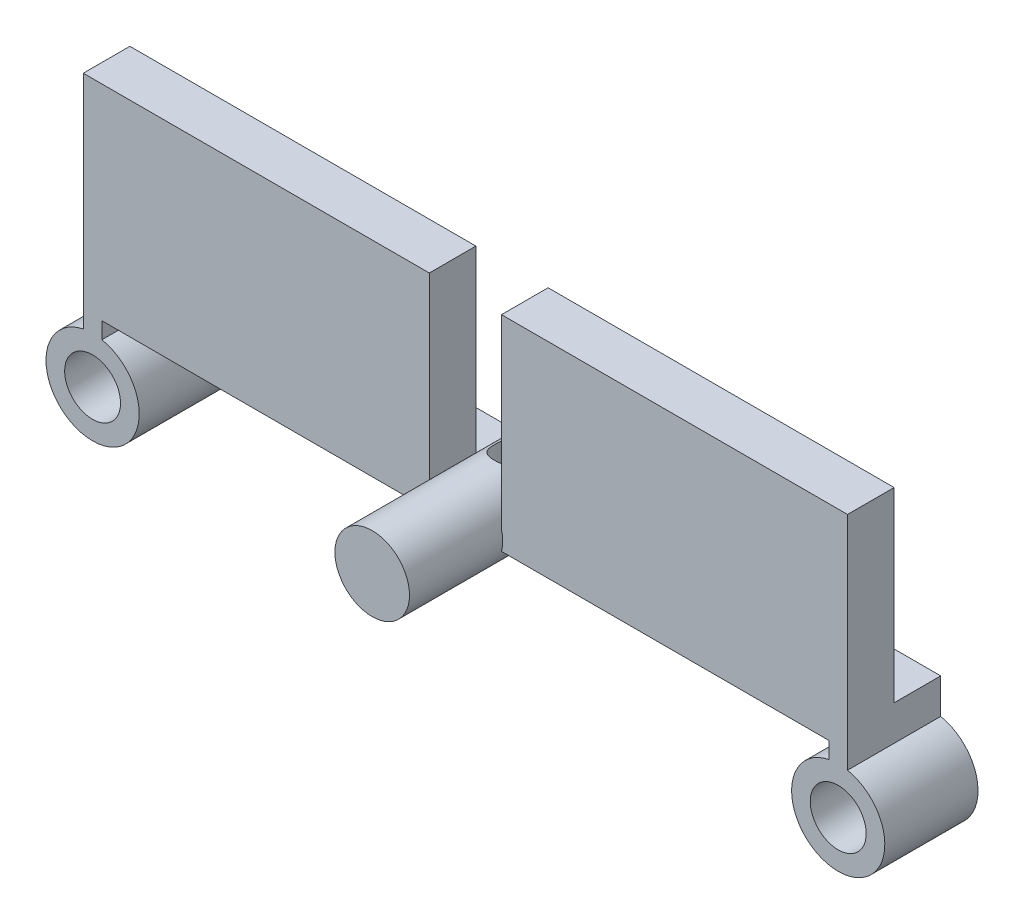
from build123d import *

# Parameters (mm, degrees)
SKETCH1_R                      = 6
BOSS_EXTRUDE1_DEPTH            = 30
SKETCH2_R                      = 4.5
BOSS_EXTRUDE2_DEPTH            = 15
CUT_EXTRUDE1_REACH             = 21
SKETCH3_R                      = 2.868632687
CUT_EXTRUDE1_DIRECTION_2_REACH = 8
SKETCH4_W                      = 55.690524981
SKETCH4_H                      = 7.5
BOSS_EXTRUDE3_DEPTH            = 30


with BuildPart() as part:
    # Sketch1 → Boss-Extrude1 (new body)
    with BuildSketch(Plane.XY):
        Circle(SKETCH1_R)
    extrude(amount=BOSS_EXTRUDE1_DEPTH)

    # Sketch2 → Boss-Extrude2 (add)
    with BuildSketch(Plane.XY):
        with BuildLine():
            Line((6, -1.5), (58.5, -1.5))
            Line((58.5, -1.5), (58.5, -4.151530772))
            ThreePointArc((58.5, -4.151530772), (60, -19), (61.5, -4.151530772))
            Line((61.5, -4.151530772), (61.5, 1.5))
            Line((61.5, 1.5), (6, 1.5))
            Line((6, 1.5), (5.809475019, 1.5))
            ThreePointArc((5.809475019, 1.5), (6, 0), (5.809475019, -1.5))
            Line((5.809475019, -1.5), (6, -1.5))
        make_face()
        with Locations((60, -11.5)):
            Circle(SKETCH2_R, mode=Mode.SUBTRACT)
        with BuildLine():
            Line((-58.5, -1.5), (-58.5, -4.151530772))
            ThreePointArc((-58.5, -4.151530772), (-60, -19), (-61.5, -4.151530772))
            Line((-61.5, -4.151530772), (-61.5, 1.5))
            Line((-61.5, 1.5), (-6, 1.5))
            Line((-6, 1.5), (-5.809475019, 1.5))
            ThreePointArc((-5.809475019, 1.5), (-6, 0), (-5.809475019, -1.5))
            Line((-5.809475019, -1.5), (-6, -1.5))
            Line((-6, -1.5), (-58.5, -1.5))
        make_face()
        with Locations((-60, -11.5)):
            Circle(SKETCH2_R, mode=Mode.SUBTRACT)
    extrude(amount=BOSS_EXTRUDE2_DEPTH)

    # Sketch3 → Cut-Extrude1 (cut, up to next)
    with BuildSketch(Plane(origin=(0, 0, 0), x_dir=(1, 0, 0), z_dir=(0, 1, 0)), mode=Mode.PRIVATE) as cut_extrude1_sk1:
        with Locations((0, -7.5)):
            Circle(SKETCH3_R)
    cut_extrude1_tool1 = extrude(cut_extrude1_sk1.sketch, amount=-CUT_EXTRUDE1_REACH, mode=Mode.PRIVATE) & part.part
    add(cut_extrude1_tool1.solids().sort_by_distance((0, 0, 7.5))[0], mode=Mode.SUBTRACT)

    # Sketch3 → Cut-Extrude1 direction 2 (cut, up to next)
    with BuildSketch(Plane(origin=(0, 0, 0), x_dir=(1, 0, 0), z_dir=(0, 1, 0)), mode=Mode.PRIVATE) as cut_extrude1_direction_2_sk1:
        with Locations((0, -7.5)):
            Circle(SKETCH3_R)
    cut_extrude1_direction_2_tool1 = extrude(cut_extrude1_direction_2_sk1.sketch, amount=CUT_EXTRUDE1_DIRECTION_2_REACH, mode=Mode.PRIVATE) & part.part
    add(cut_extrude1_direction_2_tool1.solids().sort_by_distance((0, 0, 7.5))[0], mode=Mode.SUBTRACT)

    # Sketch4 → Boss-Extrude3 (add)
    with BuildSketch(Plane(origin=(0, 1.5, 0), x_dir=(1, 0, 0), z_dir=(0, 1, 0))):
        with Locations((-33.65473751, -11.25)):
            Rectangle(SKETCH4_W, SKETCH4_H)
        with Locations((33.65473751, -11.25)):
            Rectangle(SKETCH4_W, SKETCH4_H)
    extrude(amount=BOSS_EXTRUDE3_DEPTH)


solid = part.part
